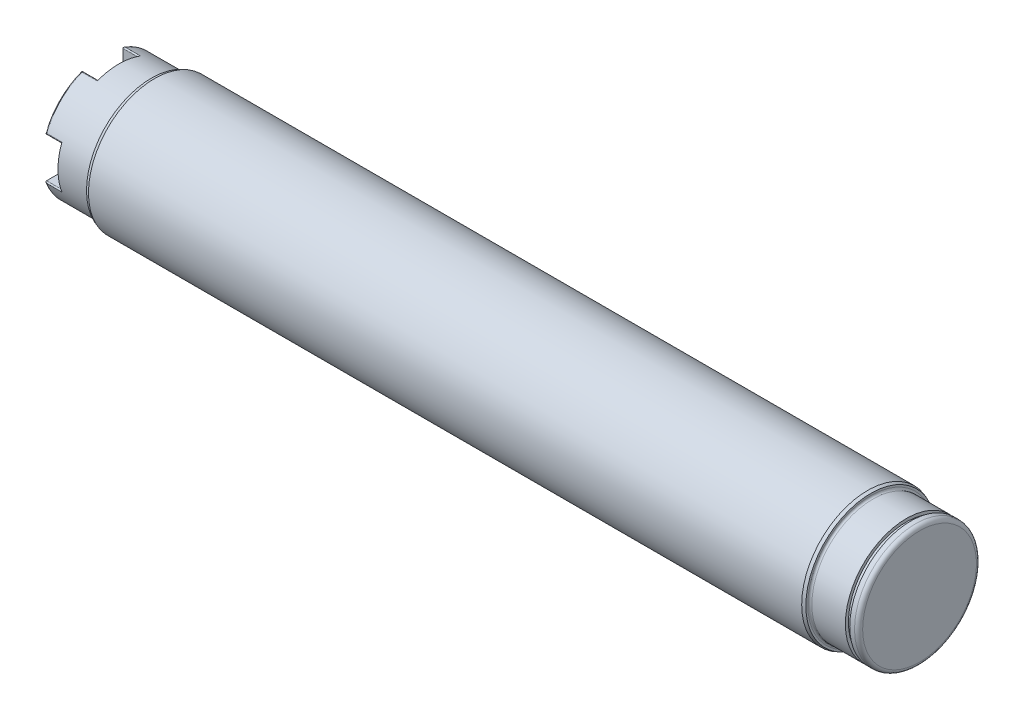
from build123d import *

# Parameters (mm, degrees)
R1_RUNDING_R     = 1
AFFR_SNING_DEPTH = 8
R0_5_RUNDINGER_R = 0.5


with BuildPart() as part:
    # Sketch1 → Base-Revolve (revolve)
    with BuildSketch(Plane.XY):
        with BuildLine():
            Line((-201, 20), (-201, 30))
            Line((-201, 30), (-177, 30))
            Line((-177, 30), (-177, 31.954044649))
            Line((-177, 31.954044649), (-175.5, 32.5))
            Line((-175.5, 32.5), (175.5, 32.5))
            Line((175.5, 32.5), (177, 31.954044649))
            Line((177, 31.954044649), (177, 30))
            Line((177, 30), (194.5, 30))
            Line((194.5, 30), (194.5, 28.5))
            Line((194.5, 28.5), (196.65, 28.5))
            Line((196.65, 28.5), (196.65, 30))
            Line((196.65, 30), (199, 30))
            ThreePointArc((199, 30), (200.414213562, 29.414213562), (201, 28))
            Line((201, 28), (201, 0))
            Line((201, 0), (-146.793975667, 0))
            Line((-146.793975667, 0), (-151, 7))
            Line((-151, 7), (-182.098709071, 7))
            Line((-182.098709071, 7), (-183, 8.5))
            Line((-183, 8.5), (-193, 8.5))
            Line((-193, 8.5), (-193, 20))
            Line((-193, 20), (-201, 20))
        make_face()
    revolve(axis=Axis((-283, 0, 0), (1, 0, 0)))

    # R1 runding
    r1_runding_edges = [part.edges().sort_by_distance(p)[0] for p in [
        (-177, -30, 0),
        (177, -30, 0),
    ]]
    fillet(r1_runding_edges, radius=R1_RUNDING_R)

    # Sketch3 → Affræsning (cut)
    with BuildSketch(Plane.ZY.offset(201)):
        with BuildLine():
            Line((10, 28.284271247), (10, 17.320508076))
            ThreePointArc((10, 17.320508076), (0, 20), (-10, 17.320508076))
            Line((-10, 17.320508076), (-10, 28.284271247))
            ThreePointArc((-10, 28.284271247), (0, 30), (10, 28.284271247))
        make_face()
        with BuildLine():
            Line((17.320508076, 10), (28.284271247, 10))
            ThreePointArc((28.284271247, 10), (30, 0), (28.284271247, -10))
            Line((28.284271247, -10), (17.320508076, -10))
            ThreePointArc((17.320508076, -10), (20, 0), (17.320508076, 10))
        make_face()
        with BuildLine():
            Line((-17.320508076, -10), (-28.284271247, -10))
            ThreePointArc((-28.284271247, -10), (-30, 0), (-28.284271247, 10))
            Line((-28.284271247, 10), (-17.320508076, 10))
            ThreePointArc((-17.320508076, 10), (-20, 0), (-17.320508076, -10))
        make_face()
        with BuildLine():
            Line((-10, -28.284271247), (-10, -17.320508076))
            ThreePointArc((-10, -17.320508076), (0, -20), (10, -17.320508076))
            Line((10, -17.320508076), (10, -28.284271247))
            ThreePointArc((10, -28.284271247), (0, -30), (-10, -28.284271247))
        make_face()
    extrude(amount=-AFFR_SNING_DEPTH, mode=Mode.SUBTRACT)

    # R0.5 rundinger
    r0_5_rundinger_edges = [part.edges().sort_by_distance(p)[0] for p in [
        (-201, 21.213203436, -21.213203436),
        (-197, 28.284271247, -10),
        (-197, 28.284271247, 10),
        (-197, 17.320508076, 10),
        (-197, 17.320508076, -10),
        (-201, 21.213203436, 21.213203436),
        (-197, -10, 17.320508076),
        (-197, 10, 17.320508076),
        (-197, 10, 28.284271247),
        (-197, -10, 28.284271247),
        (-201, -21.213203436, -21.213203436),
        (-197, 10, -17.320508076),
        (-197, -10, -17.320508076),
        (-197, -10, -28.284271247),
        (-197, 10, -28.284271247),
        (-201, -21.213203436, 21.213203436),
        (-197, -28.284271247, 10),
        (-197, -28.284271247, -10),
        (-197, -17.320508076, -10),
        (-197, -17.320508076, 10),
    ]]
    fillet(r0_5_rundinger_edges, radius=R0_5_RUNDINGER_R)


solid = part.part
